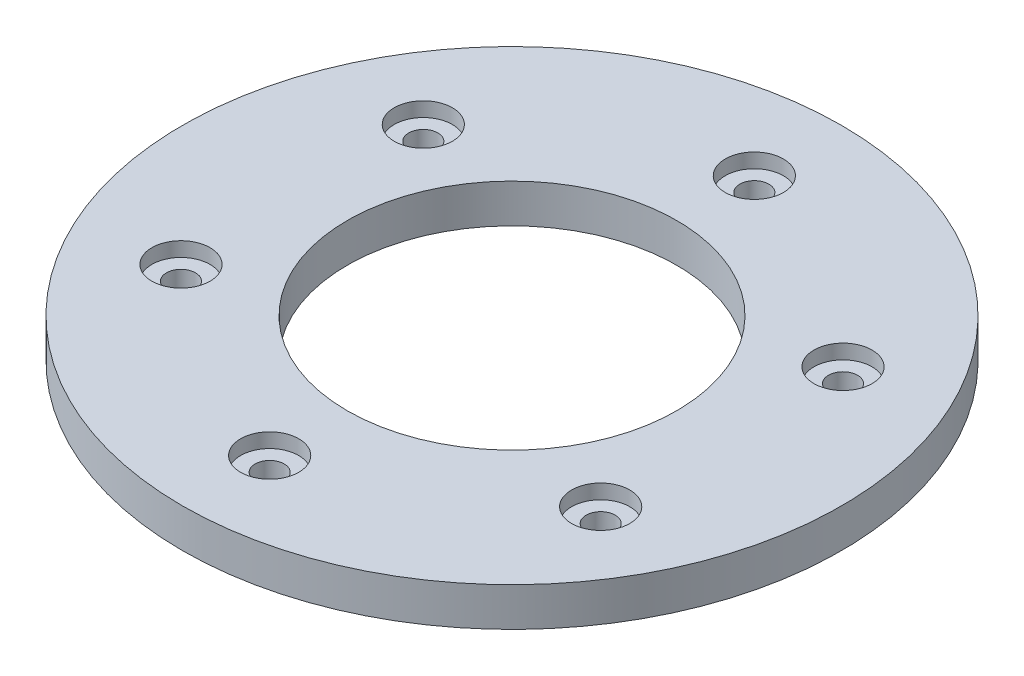
from build123d import *

# Parameters (mm, degrees)
SKETCH1_R           = 34
BOSS_EXTRUDE1_DEPTH = 4
HOLE1_D             = 3
HOLE1_DEPTH         = 5
HOLE1_CBORE_D       = 6
HOLE1_CBORE_DEPTH   = 1.5
SKETCH2_R           = 17
CUT_EXTRUDE1_DEPTH  = 5


with BuildPart() as part:
    # Sketch1 → Boss-Extrude1 (new body)
    with BuildSketch(Plane(origin=(0, 0, 0), x_dir=(1, 0, 0), z_dir=(0, 1, 0))):
        Circle(SKETCH1_R)
    extrude(amount=BOSS_EXTRUDE1_DEPTH)

    # Hole1
    with Locations(Plane(origin=(0, 4, -25), x_dir=(0, 0, 1), z_dir=(0, 1, 0))):
        with Locations((0, 0), (12.5, 21.650635095), (37.5, 21.650635095), (50, 0), (37.5, -21.650635095), (12.5, -21.650635095)):
            CounterBoreHole(HOLE1_D / 2, HOLE1_CBORE_D / 2, HOLE1_CBORE_DEPTH, depth=HOLE1_DEPTH)

    # Sketch2 → Cut-Extrude1 (cut)
    with BuildSketch(Plane(origin=(0, 4, 0), x_dir=(1, 0, 0), z_dir=(0, 1, 0))):
        Circle(SKETCH2_R)
    extrude(amount=-CUT_EXTRUDE1_DEPTH, mode=Mode.SUBTRACT)


solid = part.part
